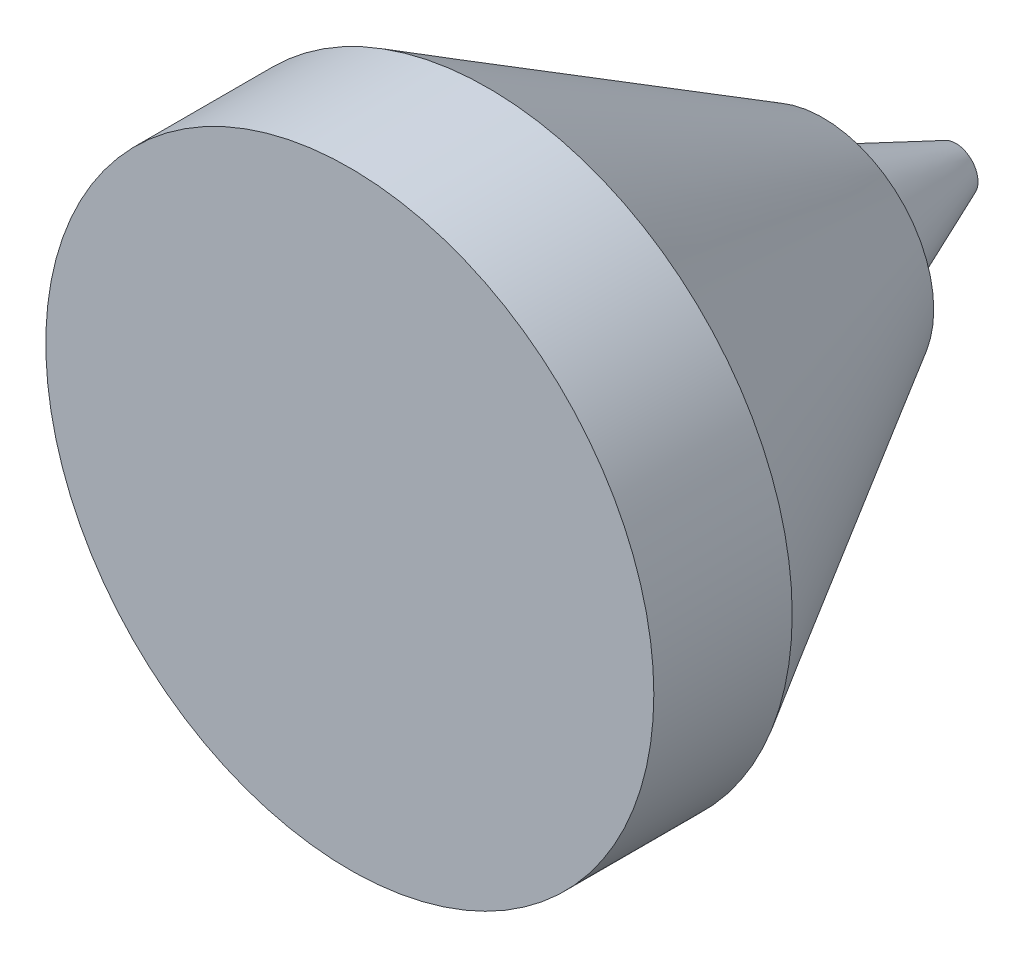
from build123d import *

# Parameters (mm, degrees)
ESQUISSE2_R             = 15.4
ENL_V_MAT_EXTRU_1_DEPTH = 54


with BuildPart() as part:
    # Esquisse1 → Révolution1 (revolve)
    with BuildSketch(Plane(origin=(0, 0, 0), x_dir=(0, 0, -1), z_dir=(1, 0, 0))):
        Polygon((-30.55, 10.985938257), (-35.55, 10.985938257), (-35.55, 0), (35.55, 0), (35.55, 15.4), (30.55, 15.4), (-18.45, 4), align=None)
    revolve(axis=Axis((0, 0, 35.55), (0, 0, -1)))

    # Esquisse2 → Enlèv. mat.-Extru.1 (cut)
    with BuildSketch(Plane.XY.offset(18.45)):
        Circle(ESQUISSE2_R)
    extrude(amount=-ENL_V_MAT_EXTRU_1_DEPTH, mode=Mode.SUBTRACT)

    # Esquisse6 → Révolution2 (revolve)
    with BuildSketch(Plane(origin=(0, 0, 0), x_dir=(0, 0, -1), z_dir=(1, 0, 0))):
        Polygon((-18.45, 2.8), (-13.65, 0.8), (-13.65, 0), (-18.45, 0), align=None)
    revolve(axis=Axis((0, 0, 13.65), (0, 0, 1)))


solid = part.part
